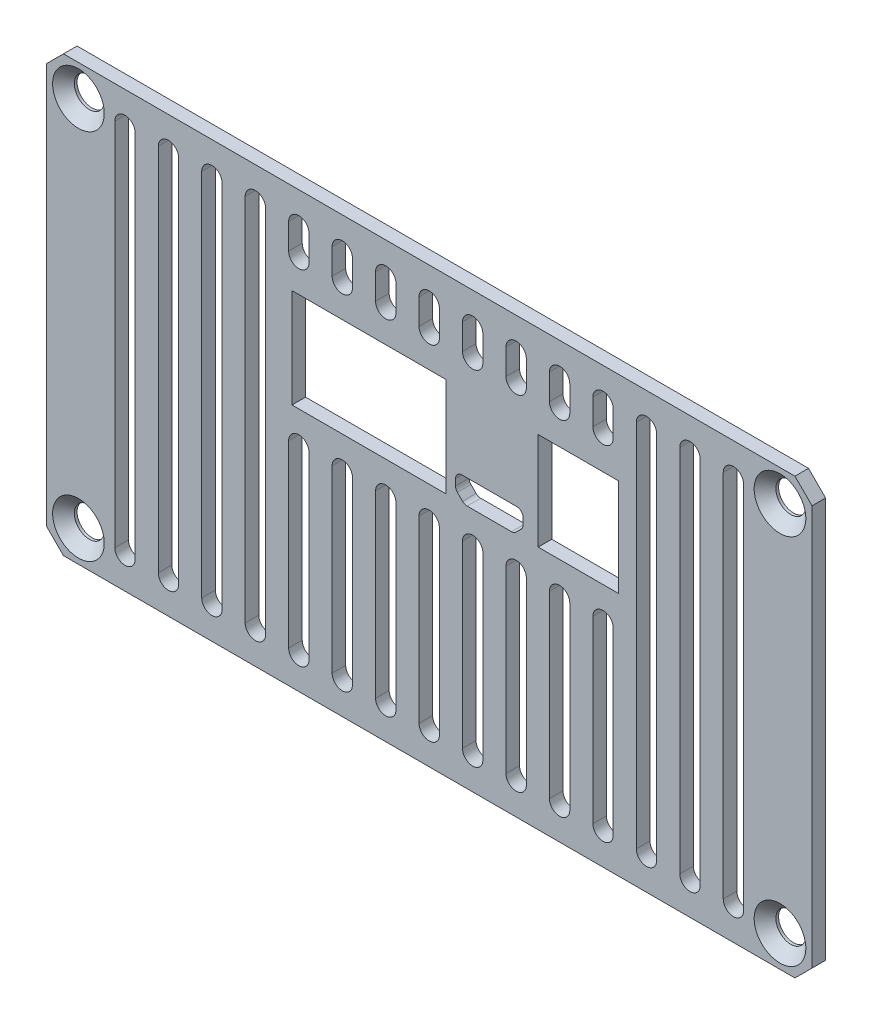
from build123d import *

# Parameters (mm, degrees)
SKETCH1_W           = 89.5
SKETCH1_H           = 50.8
BOSS_EXTRUDE1_DEPTH = 1.5875
CHAMFER1_SIZE       = 2
SKETCH2_W           = 17.9768
SKETCH2_H           = 11.576
SKETCH2_W_2         = 9.4
SKETCH2_H_2         = 11.4
CUT_EXTRUDE1_DEPTH  = 2.5875
SKETCH3_R           = 1.75
CUT_EXTRUDE2_DEPTH  = 2.5875
CHAMFER2_SIZE       = 1.27
CUT_EXTRUDE3_DEPTH  = 2.5875


with BuildPart() as part:
    # Sketch1 → Boss-Extrude1 (new body)
    with BuildSketch(Plane.XY):
        with Locations((44.75, 25.4)):
            Rectangle(SKETCH1_W, SKETCH1_H)
    extrude(amount=BOSS_EXTRUDE1_DEPTH)

    # Chamfer1
    chamfer1_edges = [part.edges().sort_by_distance(p)[0] for p in [
        (0, 50.8, 0.79375),
        (89.5, 50.8, 0.79375),
        (89.5, 0, 0.79375),
        (0, 0, 0.79375),
    ]]
    chamfer(chamfer1_edges, length=CHAMFER1_SIZE)

    # Sketch2 → Cut-Extrude1 (cut, through all)
    with BuildSketch(Plane.XY.offset(1.5875)):
        with Locations((37.701291048, 34.400499876)):
            Rectangle(SKETCH2_W, SKETCH2_H)
        with Locations((62.186773048, 34.312499876)):
            Rectangle(SKETCH2_W_2, SKETCH2_H_2)
        with BuildLine():
            Line((55.722947048, 29.966053267), (55.722947048, 30.712499876))
            ThreePointArc((55.722947048, 30.712499876), (55.503277134, 31.242829962), (54.972947048, 31.462499876))
            Line((54.972947048, 31.462499876), (48.572947048, 31.462499876))
            ThreePointArc((48.572947048, 31.462499876), (48.042616962, 31.242829962), (47.822947048, 30.712499876))
            Line((47.822947048, 30.712499876), (47.822947048, 29.966053267))
            ThreePointArc((47.822947048, 29.966053267), (47.880037399, 29.679040693), (48.042616962, 29.435723181))
            Line((48.042616962, 29.435723181), (48.646170353, 28.83216979))
            ThreePointArc((48.646170353, 28.83216979), (48.889487865, 28.669590227), (49.176500439, 28.612499876))
            Line((49.176500439, 28.612499876), (54.369393658, 28.612499876))
            ThreePointArc((54.369393658, 28.612499876), (54.656406232, 28.669590227), (54.899723744, 28.83216979))
            Line((54.899723744, 28.83216979), (55.503277134, 29.435723181))
            ThreePointArc((55.503277134, 29.435723181), (55.665856698, 29.679040693), (55.722947048, 29.966053267))
        make_face()
    extrude(amount=-CUT_EXTRUDE1_DEPTH, mode=Mode.SUBTRACT)

    # Sketch3 → Cut-Extrude2 (cut, through all)
    with BuildSketch(Plane.XY.offset(1.5875)):
        with Locations((3.75, 47.15)):
            Circle(SKETCH3_R)
        with Locations((3.75, 3.65)):
            Circle(SKETCH3_R)
        with Locations((85.75, 3.65)):
            Circle(SKETCH3_R)
        with Locations((85.75, 47.15)):
            Circle(SKETCH3_R)
    extrude(amount=-CUT_EXTRUDE2_DEPTH, mode=Mode.SUBTRACT)

    # Chamfer2
    chamfer2_edges = [part.edges().sort_by_distance(p)[0] for p in [
        (2, 47.15, 1.5875),
        (2, 3.65, 1.5875),
        (84, 3.65, 1.5875),
        (84, 47.15, 1.5875),
    ]]
    chamfer(chamfer2_edges, length=CHAMFER2_SIZE)

    # Sketch4 → Cut-Extrude3 (cut, through all)
    with BuildSketch(Plane.XY.offset(1.5875)):
        with BuildLine():
            Line((71.340625, 46.99), (71.340625, 3.81))
            ThreePointArc((71.340625, 3.81), (70.15, 2.619375), (68.959375, 3.81))
            Line((68.959375, 3.81), (68.959375, 46.99))
            ThreePointArc((68.959375, 46.99), (70.15, 48.180625), (71.340625, 46.99))
        make_face()
        with BuildLine():
            Line((45.940625, 46.99), (45.940625, 43.998499876))
            ThreePointArc((45.940625, 43.998499876), (44.75, 42.807874876), (43.559375, 43.998499876))
            Line((43.559375, 43.998499876), (43.559375, 46.99))
            ThreePointArc((43.559375, 46.99), (44.75, 48.180625), (45.940625, 46.99))
        make_face()
        with BuildLine():
            Line((45.940625, 24.802499876), (45.940625, 3.81))
            ThreePointArc((45.940625, 3.81), (44.75, 2.619375), (43.559375, 3.81))
            Line((43.559375, 3.81), (43.559375, 24.802499876))
            ThreePointArc((43.559375, 24.802499876), (44.75, 25.993124876), (45.940625, 24.802499876))
        make_face()
        with BuildLine():
            Line((51.020625, 46.99), (51.020625, 43.998499876))
            ThreePointArc((51.020625, 43.998499876), (49.83, 42.807874876), (48.639375, 43.998499876))
            Line((48.639375, 43.998499876), (48.639375, 46.99))
            ThreePointArc((48.639375, 46.99), (49.83, 48.180625), (51.020625, 46.99))
        make_face()
        with BuildLine():
            Line((51.020625, 24.802499876), (51.020625, 3.81))
            ThreePointArc((51.020625, 3.81), (49.83, 2.619375), (48.639375, 3.81))
            Line((48.639375, 3.81), (48.639375, 24.802499876))
            ThreePointArc((48.639375, 24.802499876), (49.83, 25.993124876), (51.020625, 24.802499876))
        make_face()
        with BuildLine():
            Line((56.100625, 46.99), (56.100625, 43.998499876))
            ThreePointArc((56.100625, 43.998499876), (54.91, 42.807874876), (53.719375, 43.998499876))
            Line((53.719375, 43.998499876), (53.719375, 46.99))
            ThreePointArc((53.719375, 46.99), (54.91, 48.180625), (56.100625, 46.99))
        make_face()
        with BuildLine():
            Line((56.100625, 24.802499876), (56.100625, 3.81))
            ThreePointArc((56.100625, 3.81), (54.91, 2.619375), (53.719375, 3.81))
            Line((53.719375, 3.81), (53.719375, 24.802499876))
            ThreePointArc((53.719375, 24.802499876), (54.91, 25.993124876), (56.100625, 24.802499876))
        make_face()
        with BuildLine():
            Line((61.180625, 46.99), (61.180625, 43.998499876))
            ThreePointArc((61.180625, 43.998499876), (59.99, 42.807874876), (58.799375, 43.998499876))
            Line((58.799375, 43.998499876), (58.799375, 46.99))
            ThreePointArc((58.799375, 46.99), (59.99, 48.180625), (61.180625, 46.99))
        make_face()
        with BuildLine():
            Line((61.180625, 24.802499876), (61.180625, 3.81))
            ThreePointArc((61.180625, 3.81), (59.99, 2.619375), (58.799375, 3.81))
            Line((58.799375, 3.81), (58.799375, 24.802499876))
            ThreePointArc((58.799375, 24.802499876), (59.99, 25.993124876), (61.180625, 24.802499876))
        make_face()
        with BuildLine():
            Line((66.260625, 46.99), (66.260625, 43.998499876))
            ThreePointArc((66.260625, 43.998499876), (65.07, 42.807874876), (63.879375, 43.998499876))
            Line((63.879375, 43.998499876), (63.879375, 46.99))
            ThreePointArc((63.879375, 46.99), (65.07, 48.180625), (66.260625, 46.99))
        make_face()
        with BuildLine():
            Line((66.260625, 24.802499876), (66.260625, 3.81))
            ThreePointArc((66.260625, 3.81), (65.07, 2.619375), (63.879375, 3.81))
            Line((63.879375, 3.81), (63.879375, 24.802499876))
            ThreePointArc((63.879375, 24.802499876), (65.07, 25.993124876), (66.260625, 24.802499876))
        make_face()
        with BuildLine():
            Line((76.420625, 46.99), (76.420625, 3.81))
            ThreePointArc((76.420625, 3.81), (75.23, 2.619375), (74.039375, 3.81))
            Line((74.039375, 3.81), (74.039375, 46.99))
            ThreePointArc((74.039375, 46.99), (75.23, 48.180625), (76.420625, 46.99))
        make_face()
        with BuildLine():
            Line((81.500625, 46.99), (81.500625, 3.81))
            ThreePointArc((81.500625, 3.81), (80.31, 2.619375), (79.119375, 3.81))
            Line((79.119375, 3.81), (79.119375, 46.99))
            ThreePointArc((79.119375, 46.99), (80.31, 48.180625), (81.500625, 46.99))
        make_face()
        with BuildLine():
            Line((7.999375, 46.99), (7.999375, 3.81))
            ThreePointArc((7.999375, 3.81), (9.19, 2.619375), (10.380625, 3.81))
            Line((10.380625, 3.81), (10.380625, 46.99))
            ThreePointArc((10.380625, 46.99), (9.19, 48.180625), (7.999375, 46.99))
        make_face()
        with BuildLine():
            Line((13.079375, 46.99), (13.079375, 3.81))
            ThreePointArc((13.079375, 3.81), (14.27, 2.619375), (15.460625, 3.81))
            Line((15.460625, 3.81), (15.460625, 46.99))
            ThreePointArc((15.460625, 46.99), (14.27, 48.180625), (13.079375, 46.99))
        make_face()
        with BuildLine():
            Line((18.159375, 46.99), (18.159375, 3.81))
            ThreePointArc((18.159375, 3.81), (19.35, 2.619375), (20.540625, 3.81))
            Line((20.540625, 3.81), (20.540625, 46.99))
            ThreePointArc((20.540625, 46.99), (19.35, 48.180625), (18.159375, 46.99))
        make_face()
        with BuildLine():
            Line((23.239375, 46.99), (23.239375, 3.81))
            ThreePointArc((23.239375, 3.81), (24.43, 2.619375), (25.620625, 3.81))
            Line((25.620625, 3.81), (25.620625, 46.99))
            ThreePointArc((25.620625, 46.99), (24.43, 48.180625), (23.239375, 46.99))
        make_face()
        with BuildLine():
            Line((28.319375, 24.802499876), (28.319375, 3.81))
            ThreePointArc((28.319375, 3.81), (29.51, 2.619375), (30.700625, 3.81))
            Line((30.700625, 3.81), (30.700625, 24.802499876))
            ThreePointArc((30.700625, 24.802499876), (29.51, 25.993124876), (28.319375, 24.802499876))
        make_face()
        with BuildLine():
            Line((28.319375, 46.99), (28.319375, 43.998499876))
            ThreePointArc((28.319375, 43.998499876), (29.51, 42.807874876), (30.700625, 43.998499876))
            Line((30.700625, 43.998499876), (30.700625, 46.99))
            ThreePointArc((30.700625, 46.99), (29.51, 48.180625), (28.319375, 46.99))
        make_face()
        with BuildLine():
            Line((33.399375, 24.802499876), (33.399375, 3.81))
            ThreePointArc((33.399375, 3.81), (34.59, 2.619375), (35.780625, 3.81))
            Line((35.780625, 3.81), (35.780625, 24.802499876))
            ThreePointArc((35.780625, 24.802499876), (34.59, 25.993124876), (33.399375, 24.802499876))
        make_face()
        with BuildLine():
            Line((33.399375, 46.99), (33.399375, 43.998499876))
            ThreePointArc((33.399375, 43.998499876), (34.59, 42.807874876), (35.780625, 43.998499876))
            Line((35.780625, 43.998499876), (35.780625, 46.99))
            ThreePointArc((35.780625, 46.99), (34.59, 48.180625), (33.399375, 46.99))
        make_face()
        with BuildLine():
            Line((38.479375, 24.802499876), (38.479375, 3.81))
            ThreePointArc((38.479375, 3.81), (39.67, 2.619375), (40.860625, 3.81))
            Line((40.860625, 3.81), (40.860625, 24.802499876))
            ThreePointArc((40.860625, 24.802499876), (39.67, 25.993124876), (38.479375, 24.802499876))
        make_face()
        with BuildLine():
            Line((38.479375, 46.99), (38.479375, 43.998499876))
            ThreePointArc((38.479375, 43.998499876), (39.67, 42.807874876), (40.860625, 43.998499876))
            Line((40.860625, 43.998499876), (40.860625, 46.99))
            ThreePointArc((40.860625, 46.99), (39.67, 48.180625), (38.479375, 46.99))
        make_face()
    extrude(amount=-CUT_EXTRUDE3_DEPTH, mode=Mode.SUBTRACT)


solid = part.part
